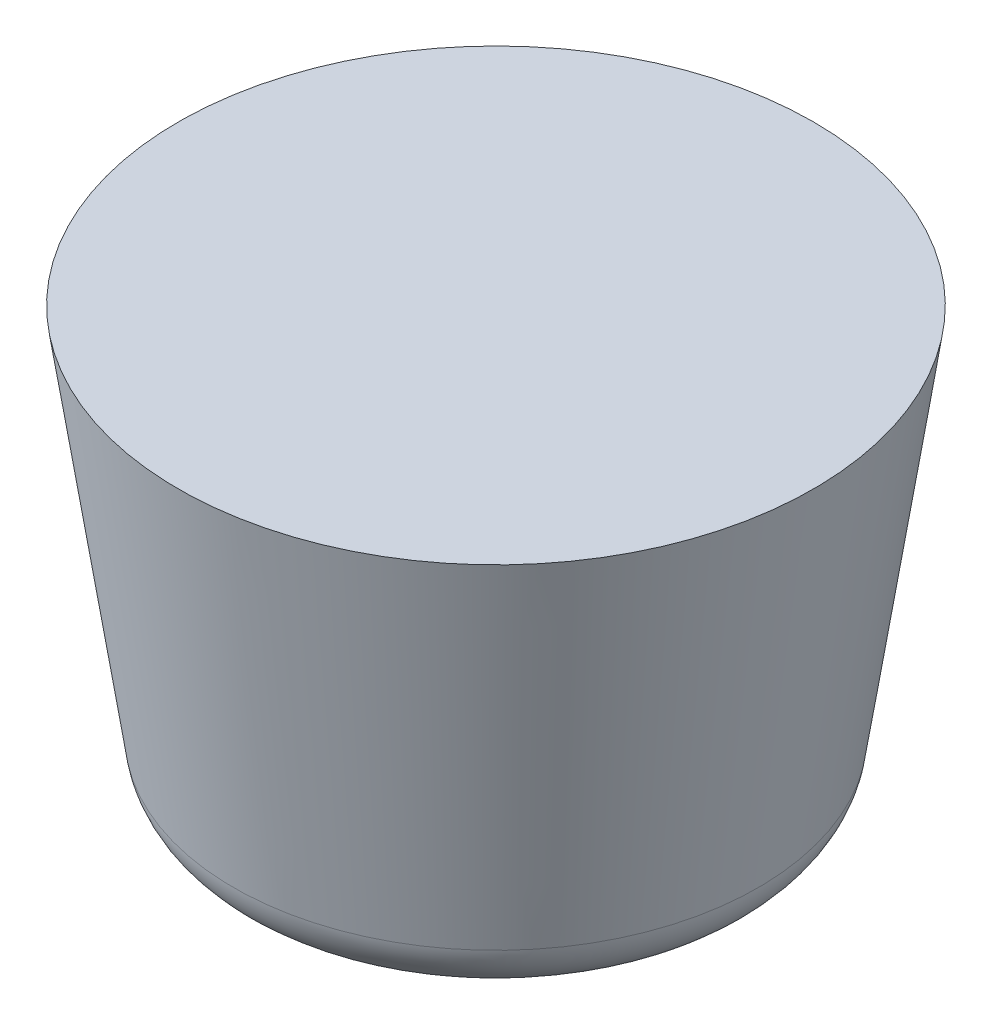
from build123d import *

# Parameters (mm, degrees)
REDONDEO1_R = 3


with BuildPart() as part:
    # Croquis1 → Revolución1 (revolve)
    with BuildSketch(Plane.XY):
        Polygon((0, 20), (15, 20), (12, -0.213469358), (0, 0), align=None)
    revolve(axis=Axis((0, 0, 0), (0, 1, 0)))

    # Redondeo1
    redondeo1_edges = [part.edges().sort_by_distance(p)[0] for p in [
        (-12, -0.213469358, 0),
    ]]
    fillet(redondeo1_edges, radius=REDONDEO1_R)


solid = part.part
